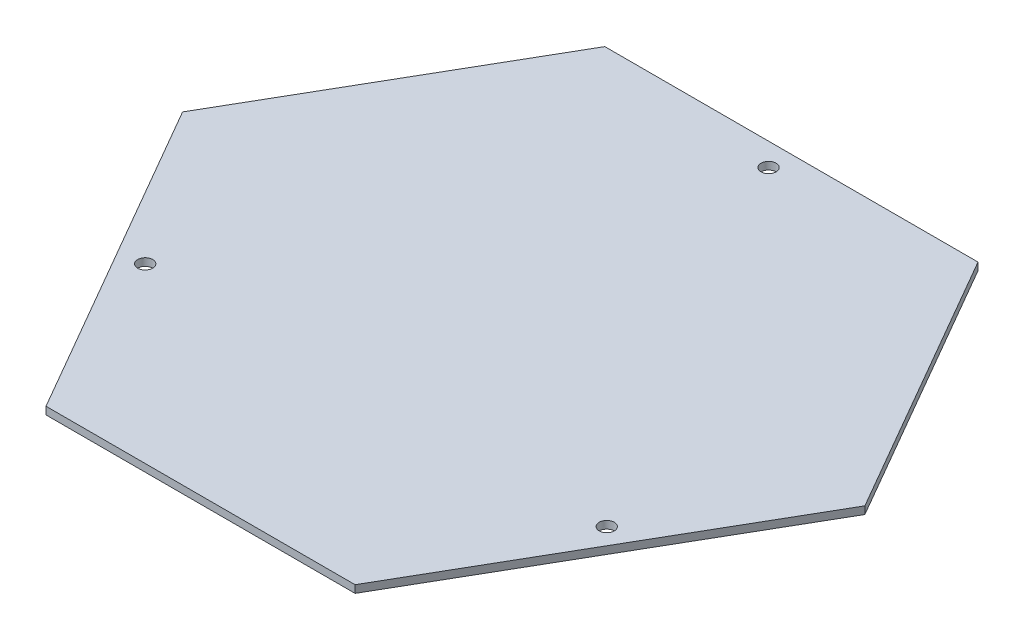
from build123d import *

# Parameters (mm, degrees)
BOSS_EXTRUDE2_DEPTH = 5
SKETCH3_R           = 5
CUT_EXTRUDE3_DEPTH  = 10


with BuildPart() as part:
    # Sketch2 → Boss-Extrude2 (new body)
    with BuildSketch(Plane(origin=(0, 0, 0), x_dir=(1, 0, 0), z_dir=(0, 1, 0))):
        Polygon((0, 0), (205, 0), (328.75, 214.341287437), (226.25, 391.876495212), (-21.25, 391.876495212), (-123.75, 214.341287437), align=None)
    extrude(amount=BOSS_EXTRUDE2_DEPTH)

    # Sketch3 → Cut-Extrude3 (cut)
    with BuildSketch(Plane(origin=(0, 5, 0), x_dir=(1, 0, 0), z_dir=(0, 1, 0))):
        with Locations((102.5, 376.721050646)):
            Circle(SKETCH3_R)
        with Locations((255.08272676, 116.819354837)):
            Circle(SKETCH3_R)
        with Locations((-48.884618943, 114.670643718)):
            Circle(SKETCH3_R)
    extrude(amount=-CUT_EXTRUDE3_DEPTH, mode=Mode.SUBTRACT)


solid = part.part
